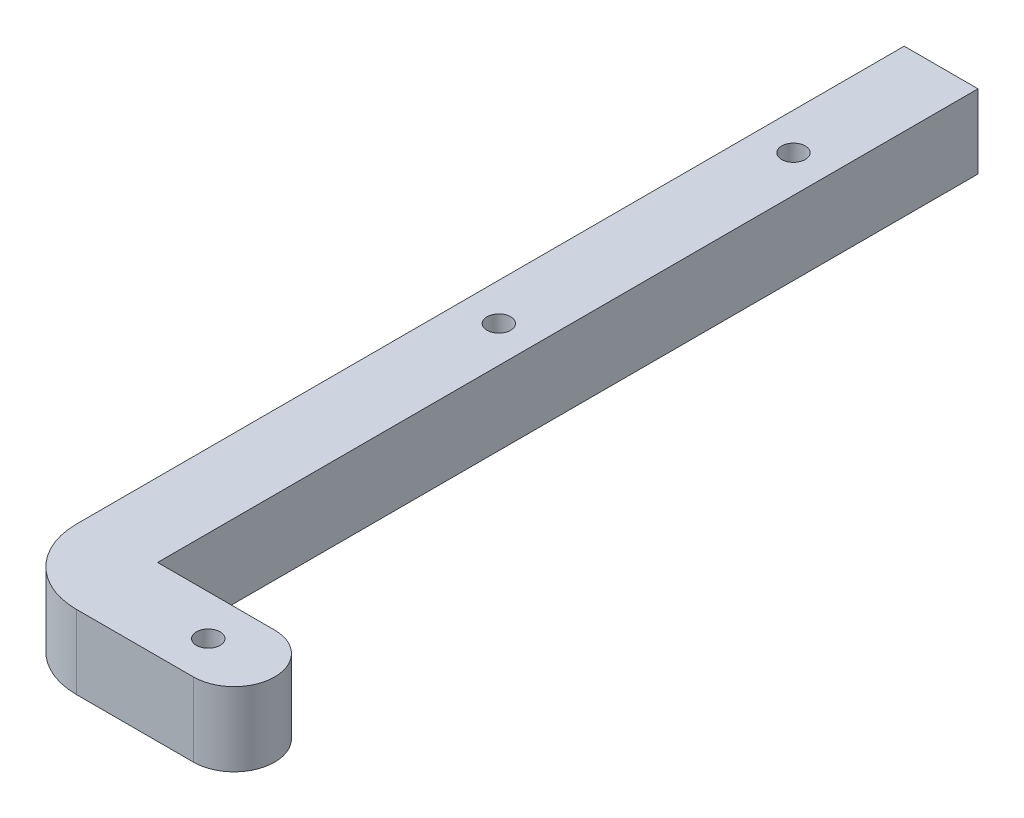
from build123d import *

# Parameters (mm, degrees)
BOSS_EXTRUDE1_DEPTH  = 10
FILLET1_R            = 10
M3_CLEARANCE_HOLE1_D = 3.2


with BuildPart() as part:
    # Sketch1 → Boss-Extrude1 (new body)
    with BuildSketch(Plane(origin=(0, 0, 0), x_dir=(1, 0, 0), z_dir=(0, 1, 0))):
        with BuildLine():
            Line((-58.140357718, 104.367316493), (-48.140357718, 104.367316493))
            Line((-48.140357718, 104.367316493), (-48.140357718, -6.785904903))
            Line((-48.140357718, -6.785904903), (-32.275583784, -6.785904903))
            ThreePointArc((-32.275583784, -6.785904903), (-26.775583784, -12.285904903), (-32.275583784, -17.785904903))
            Line((-32.275583784, -17.785904903), (-58.140357718, -17.785904903))
            Line((-58.140357718, -17.785904903), (-58.140357718, -6.785904903))
            Line((-58.140357718, -6.785904903), (-58.140357718, 104.367316493))
        make_face()
    extrude(amount=BOSS_EXTRUDE1_DEPTH)

    # Fillet1
    fillet1_edges = [part.edges().sort_by_distance(p)[0] for p in [
        (-58.140357718, 5, 17.785904903),
    ]]
    fillet(fillet1_edges, radius=FILLET1_R)

    # M3 Clearance Hole1 (through all)
    with Locations(Plane(origin=(-35.775583784, 0, 12.285904903), x_dir=(0, 0, -1), z_dir=(0, -1, 0))):
        with Locations((0, 0), (96.653221396, -17.364773934), (56.653302681, -17.284133769)):
            Hole(M3_CLEARANCE_HOLE1_D / 2)


solid = part.part
